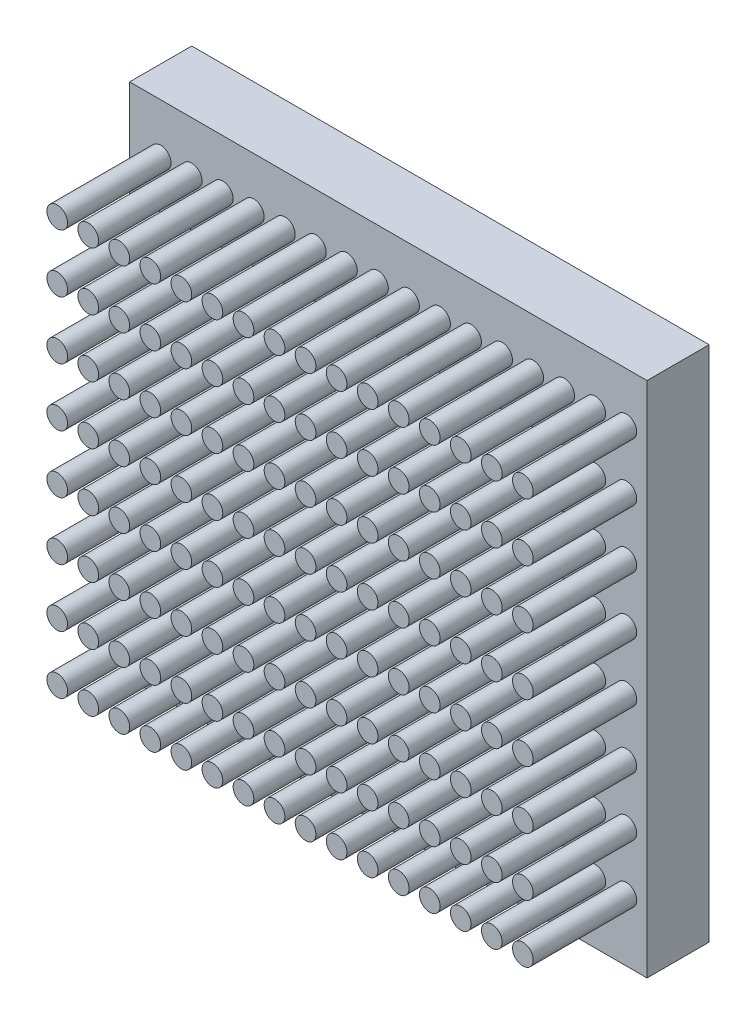
from build123d import *

# Parameters (mm, degrees)
SKETCH1_W           = 250
SKETCH1_H           = 250
BOSS_EXTRUDE1_DEPTH = 30
SKETCH2_R           = 5
BOSS_EXTRUDE2_DEPTH = 50
LPATTERN1_COUNT     = 8
LPATTERN1_PITCH     = 28


with BuildPart() as part:
    # Sketch1 → Boss-Extrude1 (new body)
    with BuildSketch(Plane.XY):
        with Locations((125, 125)):
            Rectangle(SKETCH1_W, SKETCH1_H)
    extrude(amount=BOSS_EXTRUDE1_DEPTH)

    # Sketch2 → Boss-Extrude2 (add)
    with BuildSketch(Plane.XY.offset(30)):
        with Locations((60, 30)):
            Circle(SKETCH2_R)
        with Locations((15, 30)):
            Circle(SKETCH2_R)
        with Locations((30, 30)):
            Circle(SKETCH2_R)
        with Locations((45, 30)):
            Circle(SKETCH2_R)
        with Locations((75, 30)):
            Circle(SKETCH2_R)
        with Locations((90, 30)):
            Circle(SKETCH2_R)
        with Locations((105, 30)):
            Circle(SKETCH2_R)
        with Locations((120, 30)):
            Circle(SKETCH2_R)
        with Locations((135, 30)):
            Circle(SKETCH2_R)
        with Locations((150, 30)):
            Circle(SKETCH2_R)
        with Locations((165, 30)):
            Circle(SKETCH2_R)
        with Locations((180, 30)):
            Circle(SKETCH2_R)
        with Locations((195, 30)):
            Circle(SKETCH2_R)
        with Locations((210, 30)):
            Circle(SKETCH2_R)
        with Locations((225, 30)):
            Circle(SKETCH2_R)
        with Locations((240, 30)):
            Circle(SKETCH2_R)
    boss_extrude2 = extrude(amount=BOSS_EXTRUDE2_DEPTH)

    # LPattern1: Boss-Extrude2 ×8
    with Locations(*[(0, i * LPATTERN1_PITCH, 0) for i in range(1, LPATTERN1_COUNT)]):
        add(boss_extrude2)


solid = part.part
